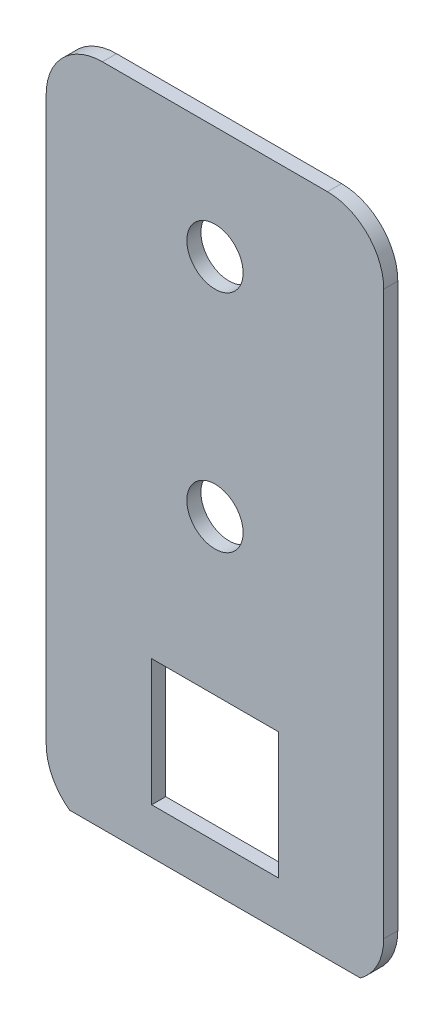
from build123d import *

# Parameters (mm, degrees)
SKETCH1_R           = 3.175
SKETCH1_W           = 14.2875
SKETCH1_H           = 14.2875
BOSS_EXTRUDE1_DEPTH = 1.5875
CUT_EXTRUDE1_DEPTH  = 76.2


with BuildPart() as part:
    # Sketch1 → Boss-Extrude1 (new body)
    with BuildSketch(Plane.XY):
        with BuildLine():
            Line((6.35, 0), (31.75, 0))
            ThreePointArc((31.75, 0), (36.240128061, 1.859871939), (38.1, 6.35))
            Line((38.1, 6.35), (38.1, 69.85))
            ThreePointArc((38.1, 69.85), (36.240128061, 74.340128061), (31.75, 76.2))
            Line((31.75, 76.2), (6.35, 76.2))
            ThreePointArc((6.35, 76.2), (1.859871939, 74.340128061), (0, 69.85))
            Line((0, 69.85), (0, 6.35))
            ThreePointArc((0, 6.35), (1.859871939, 1.859871939), (6.35, 0))
        make_face()
        with Locations((19.05, 38.1)):
            Circle(SKETCH1_R, mode=Mode.SUBTRACT)
        with Locations((19.05, 63.5)):
            Circle(SKETCH1_R, mode=Mode.SUBTRACT)
        with Locations((19.05, 13.49375)):
            Rectangle(SKETCH1_W, SKETCH1_H, mode=Mode.SUBTRACT)
    extrude(amount=BOSS_EXTRUDE1_DEPTH)

    # Sketch3 → Cut-Extrude1 (cut)
    with BuildSketch(Plane.ZY):
        Polygon((0.396875, 0), (1.5875, 1.190625), (1.5875, 0), align=None)
    extrude(amount=-CUT_EXTRUDE1_DEPTH, mode=Mode.SUBTRACT)


solid = part.part
